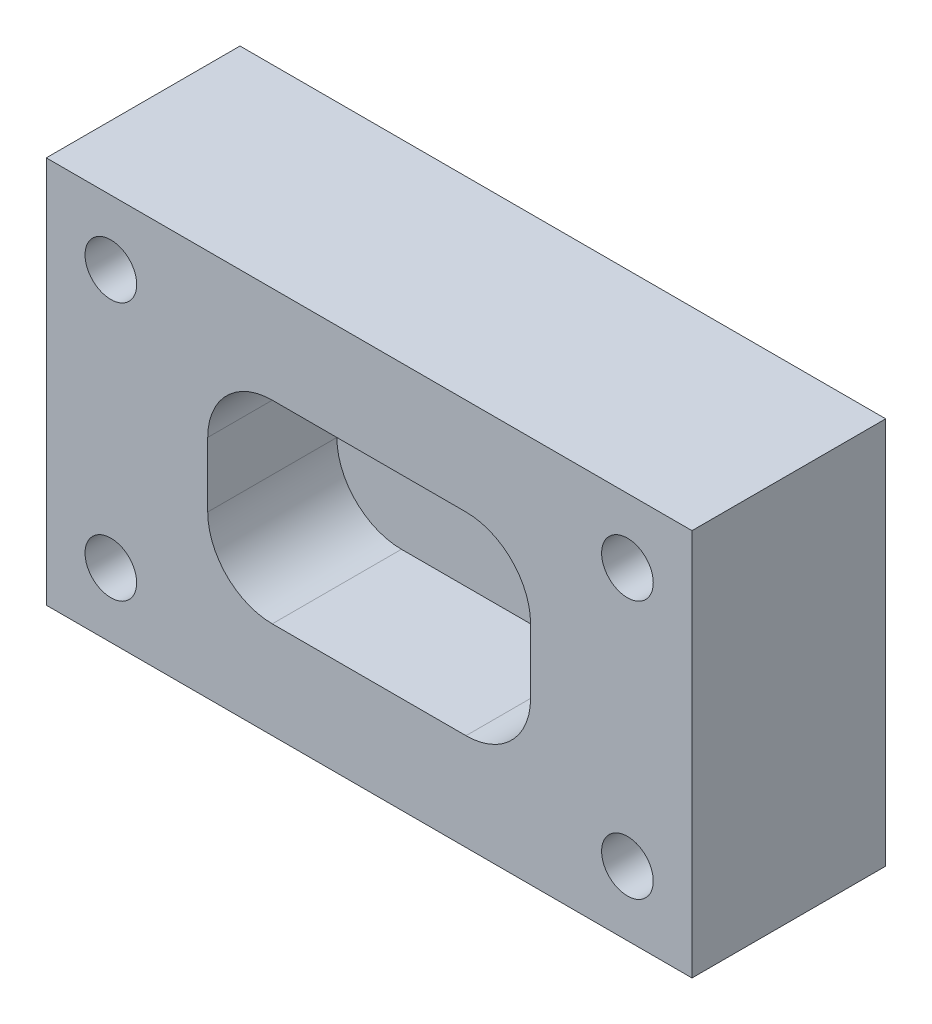
from build123d import *

# Parameters (mm, degrees)
ESBO_O1_W       = 100
ESBO_O1_H       = 60
ESBO_O1_R       = 4
EXTRUS_O2_DEPTH = 30
EXTRUS_O3_DEPTH = 20


with BuildPart() as part:
    # Esbo_o1 → Extrus_o2 (new body)
    with BuildSketch(Plane.XY):
        with Locations((50, 30)):
            Rectangle(ESBO_O1_W, ESBO_O1_H)
        with Locations((90, 10)):
            Circle(ESBO_O1_R, mode=Mode.SUBTRACT)
        with Locations((10, 10)):
            Circle(ESBO_O1_R, mode=Mode.SUBTRACT)
        with Locations((10, 50)):
            Circle(ESBO_O1_R, mode=Mode.SUBTRACT)
        with Locations((90, 50)):
            Circle(ESBO_O1_R, mode=Mode.SUBTRACT)
        with BuildLine():
            ThreePointArc((25, 25), (27.928932188, 17.928932188), (35, 15))
            Line((35, 15), (65, 15))
            ThreePointArc((65, 15), (72.071067812, 17.928932188), (75, 25))
            Line((75, 25), (75, 35))
            ThreePointArc((75, 35), (72.071067812, 42.071067812), (65, 45))
            Line((65, 45), (35, 45))
            ThreePointArc((35, 45), (27.928932188, 42.071067812), (25, 35))
            Line((25, 35), (25, 25))
        make_face(mode=Mode.SUBTRACT)
        with BuildLine():
            Line((25, 35), (25, 25))
            ThreePointArc((25, 25), (27.928932188, 17.928932188), (35, 15))
            Line((35, 15), (65, 15))
            ThreePointArc((65, 15), (72.071067812, 17.928932188), (75, 25))
            Line((75, 25), (75, 35))
            ThreePointArc((75, 35), (72.071067812, 42.071067812), (65, 45))
            Line((65, 45), (35, 45))
            ThreePointArc((35, 45), (27.928932188, 42.071067812), (25, 35))
        make_face()
    extrude(amount=-EXTRUS_O2_DEPTH)

    # Esbo_o1_4 → Extrus_o3 (cut)
    with BuildSketch(Plane.XY):
        with BuildLine():
            Line((25, 35), (25, 25))
            ThreePointArc((25, 25), (27.928932188, 17.928932188), (35, 15))
            Line((35, 15), (65, 15))
            ThreePointArc((65, 15), (72.071067812, 17.928932188), (75, 25))
            Line((75, 25), (75, 35))
            ThreePointArc((75, 35), (72.071067812, 42.071067812), (65, 45))
            Line((65, 45), (35, 45))
            ThreePointArc((35, 45), (27.928932188, 42.071067812), (25, 35))
        make_face()
    extrude(amount=-EXTRUS_O3_DEPTH, mode=Mode.SUBTRACT)


solid = part.part
